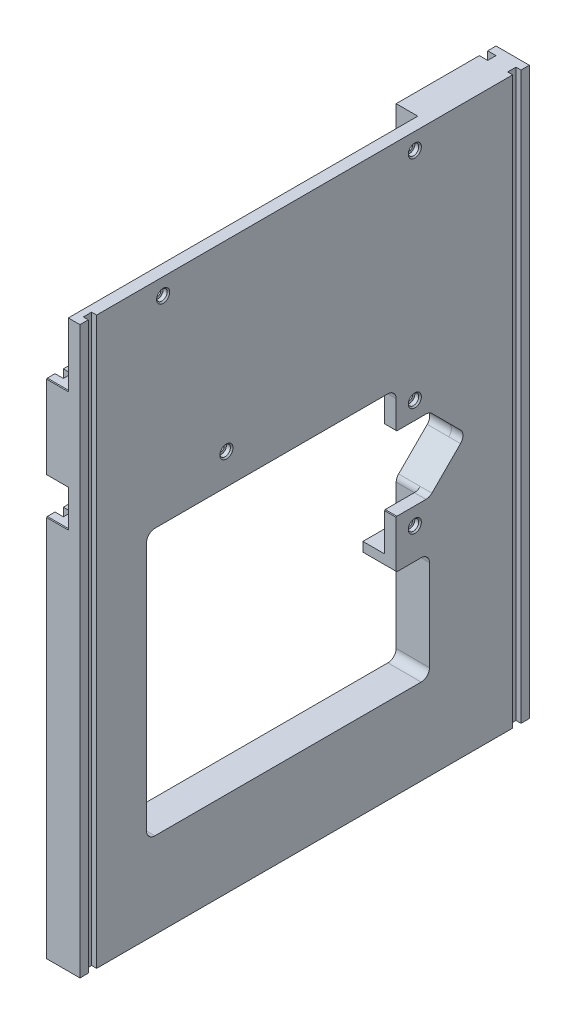
from build123d import *

# Parameters (mm, degrees)
SKETCH2_W                     = 342.9
SKETCH2_H                     = 431.8
BASE_DEPTH                    = 25.4
CUT_EXTRUDE3_REACH            = 27.4
NC_POCKET_DEPTH               = 16.51
FILLET9_R                     = 6.35
FILLET6_R                     = 6.35
CBORE_FOR_M4_SHCS1_AT_2_COUNT = 2
CBORE_FOR_M4_SHCS1_AT_2_PITCH = 192.024
CBORE_FOR_M4_SHCS1_AT_3_COUNT = 2
CBORE_FOR_M4_SHCS1_AT_3_PITCH = 313.675937134
CBORE_FOR_M4_SHCS1_AT_4_COUNT = 2
CBORE_FOR_M4_SHCS1_AT_4_PITCH = 253.241439295
CBORE_FOR_M4_SHCS1_AT_5_COUNT = 2
CBORE_FOR_M4_SHCS1_AT_5_PITCH = 135.860323862
SKETCH18_R                    = 7.1755
CUT_EXTRUDE4_DEPTH            = 1.016
F_3_8_16_TAPPED_HOLE1_D       = 7.9375
F_3_8_16_TAPPED_HOLE1_DEPTH   = 27.94
F_3_8_16_TAPPED_HOLE1_TIP     = 2.384665582
F_3_8_16_TAPPED_HOLE2_D       = 7.9375
F_3_8_16_TAPPED_HOLE2_DEPTH   = 20.32
F_3_8_16_TAPPED_HOLE2_TIP     = 2.384665582
CUT_EXTRUDE5_REACH            = 10.89
FILLET1_R                     = 6.35
FILLET2_R                     = 6.35
CHAMFER1_SIZE                 = 0.508
SKETCH21_W                    = 6.35
SKETCH21_H                    = 431.8
CUT_EXTRUDE6_DEPTH            = 6.35
SKETCH22_W                    = 6.35
SKETCH22_H                    = 431.8
CUT_EXTRUDE7_DEPTH            = 3.81


with BuildPart() as part:
    # Sketch2 → Base (new body)
    with BuildSketch(Plane(origin=(0, 0, 0), x_dir=(0, 0, -1), z_dir=(1, 0, 0))):
        with Locations((-44.038996764, -78.624919094)):
            Rectangle(SKETCH2_W, SKETCH2_H)
    extrude(amount=BASE_DEPTH)

    # Sketch3 → Cut-Extrude3 (cut, up to next)
    with BuildSketch(Plane(origin=(0, 0, 0), x_dir=(0, 0, -1), z_dir=(1, 0, 0)), mode=Mode.PRIVATE) as cut_extrude3_sk1:
        Polygon((-164.688996764, -25.919919094), (-164.688996764, -229.119919094), (51.211003236, -229.119919094), (51.211003236, -146.950919094), (25.811003236, -146.950919094), (25.811003236, -25.919919094), align=None)
    cut_extrude3_tool1 = extrude(cut_extrude3_sk1.sketch, amount=CUT_EXTRUDE3_REACH, mode=Mode.PRIVATE) & part.part
    add(cut_extrude3_tool1.solids().sort_by_distance((0, -130.615794, 63.91645))[0], mode=Mode.SUBTRACT)

    # Sketch4 → NC pocket (cut)
    with BuildSketch(Plane(origin=(0, 0, 0), x_dir=(0, 0, -1), z_dir=(1, 0, 0))):
        Polygon((19.461003236, -18.299919094), (-158.338996764, -18.299919094), (-158.338996764, -25.919919094), (-164.688996764, -25.919919094), (-164.688996764, -12.583714933), (-164.688996764, -2.424919094), (-215.488996764, -2.424919094), (-215.488996764, 24.880080906), (-164.688996764, 24.880080906), (-164.688996764, 89.015080906), (-215.488996764, 89.015080906), (-215.488996764, 90.285080906), (-215.488996764, 137.275080906), (-202.788996764, 137.275080906), (51.211003236, 137.275080906), (51.211003236, -15.124919094), (51.211003236, -53.859919094), (79.405003236, -82.053919094), (51.211003236, -110.247919094), (51.211003236, -136.155919094), (51.211003236, -146.950919094), (44.861003236, -146.950919094), (44.861003236, -139.330919094), (25.811003236, -139.330919094), (25.811003236, -25.919919094), (19.461003236, -25.919919094), align=None)
    extrude(amount=NC_POCKET_DEPTH, mode=Mode.SUBTRACT)

    # Fillet9
    fillet9_edges = [part.edges().sort_by_distance(p)[0] for p in [
        (8.255, -53.859919094, -51.211003236),
        (8.255, -110.247919094, -51.211003236),
    ]]
    fillet(fillet9_edges, radius=FILLET9_R)

    # Fillet6
    fillet6_edges = [part.edges().sort_by_distance(p)[0] for p in [
        (8.255, -82.053919094, -79.405003236),
    ]]
    fillet(fillet6_edges, radius=FILLET6_R)

    # Sketch10 → CBORE for M4 SHCS1 (revolve, cut)
    with BuildSketch(Plane(origin=(25.4, 124.575080906, 151.988996764), x_dir=(0, 0, -1), z_dir=(0, 1, 0))):
        Polygon((0, 0), (0, 8.89), (2.15, 8.89), (2.15, 4), (4, 4), (4, 1), (5, 0), align=None)
    cbore_for_m4_shcs1 = revolve(axis=Axis((31.75, 124.575080906, 151.988996764), (-1, 0, 0)), mode=Mode.SUBTRACT)

    # CBORE for M4 SHCS1 at 2: CBORE for M4 SHCS1 ×2
    with Locations(*[(0, 0, -i * CBORE_FOR_M4_SHCS1_AT_2_PITCH) for i in range(1, CBORE_FOR_M4_SHCS1_AT_2_COUNT)]):
        add(cbore_for_m4_shcs1, mode=Mode.SUBTRACT)

    # CBORE for M4 SHCS1 at 3: CBORE for M4 SHCS1 ×2
    with Locations(*[Vector(0, -0.790723708, -0.612173193) * (i * CBORE_FOR_M4_SHCS1_AT_3_PITCH) for i in range(1, CBORE_FOR_M4_SHCS1_AT_3_COUNT)]):
        add(cbore_for_m4_shcs1, mode=Mode.SUBTRACT)

    # CBORE for M4 SHCS1 at 4: CBORE for M4 SHCS1 ×2
    with Locations(*[Vector(0, -0.651947013, -0.758264526) * (i * CBORE_FOR_M4_SHCS1_AT_4_PITCH) for i in range(1, CBORE_FOR_M4_SHCS1_AT_4_COUNT)]):
        add(cbore_for_m4_shcs1, mode=Mode.SUBTRACT)

    # CBORE for M4 SHCS1 at 5: CBORE for M4 SHCS1 ×2
    with Locations(*[Vector(0, -0.934783581, -0.355217761) * (i * CBORE_FOR_M4_SHCS1_AT_5_PITCH) for i in range(1, CBORE_FOR_M4_SHCS1_AT_5_COUNT)]):
        add(cbore_for_m4_shcs1, mode=Mode.SUBTRACT)

    # Sketch18 → Cut-Extrude4 (cut)
    with BuildSketch(Plane.ZY.offset(-16.51)):
        with Locations((-40.035003236, 124.575080906)):
            Circle(SKETCH18_R)
        with Locations((151.988996764, 124.575080906)):
            Circle(SKETCH18_R)
        with Locations((103.728996764, -2.424919094)):
            Circle(SKETCH18_R)
        with Locations((-40.035003236, -40.524919094)):
            Circle(SKETCH18_R)
        with Locations((-40.035003236, -123.455919094)):
            Circle(SKETCH18_R)
    extrude(amount=-CUT_EXTRUDE4_DEPTH, mode=Mode.SUBTRACT)

    # 3/8-16 Tapped Hole1
    with Locations(Plane(origin=(12.7, -294.524919094, -70.261003236), x_dir=(0, 0, -1), z_dir=(0, -1, 0))):
        with Locations((0, 0), (-114.3, 0), (-228.6, 0)):
            Hole(F_3_8_16_TAPPED_HOLE1_D / 2, depth=F_3_8_16_TAPPED_HOLE1_DEPTH)
            with Locations((0, 0, -(F_3_8_16_TAPPED_HOLE1_DEPTH + F_3_8_16_TAPPED_HOLE1_TIP / 2))):  # 118° drill point
                Cone(0, F_3_8_16_TAPPED_HOLE1_D / 2, F_3_8_16_TAPPED_HOLE1_TIP, mode=Mode.SUBTRACT)

    # 3/8-16 Tapped Hole2
    with Locations(Plane.ZY):
        with Locations((190.088996764, -220.864919094), (190.088996764, -162.444919094), (-102.011003236, -220.864919094), (-102.011003236, -162.444919094)):
            Hole(F_3_8_16_TAPPED_HOLE2_D / 2, depth=F_3_8_16_TAPPED_HOLE2_DEPTH)
            with Locations((0, 0, -(F_3_8_16_TAPPED_HOLE2_DEPTH + F_3_8_16_TAPPED_HOLE2_TIP / 2))):  # 118° drill point
                Cone(0, F_3_8_16_TAPPED_HOLE2_D / 2, F_3_8_16_TAPPED_HOLE2_TIP, mode=Mode.SUBTRACT)

    # Sketch20 → Cut-Extrude5 (cut, up to next)
    with BuildSketch(Plane.ZY.offset(-16.51), mode=Mode.PRIVATE) as cut_extrude5_sk1:
        Polygon((-51.211003236, -53.859919094), (-25.811003236, -53.859919094), (-25.811003236, -110.247919094), (-51.211003236, -110.247919094), (-79.405003236, -82.053919094), align=None)
    cut_extrude5_tool1 = extrude(cut_extrude5_sk1.sketch, amount=-CUT_EXTRUDE5_REACH, mode=Mode.PRIVATE) & part.part
    add(cut_extrude5_tool1.solids().sort_by_distance((16.51, -82.053919, -46.398071))[0], mode=Mode.SUBTRACT)

    # Fillet1
    fillet1_edges = [part.edges().sort_by_distance(p)[0] for p in [
        (20.955, -25.919919094, 164.688996764),
        (12.7, -229.119919094, 164.688996764),
        (12.7, -229.119919094, -51.211003236),
        (20.955, -146.950919094, -51.211003236),
        (20.955, -25.919919094, -25.811003236),
    ]]
    fillet(fillet1_edges, radius=FILLET1_R)

    # Fillet2
    fillet2_edges = [part.edges().sort_by_distance(p)[0] for p in [
        (20.955, -82.053919094, -79.405003236),
        (20.955, -110.247919094, -51.211003236),
        (20.955, -53.859919094, -51.211003236),
    ]]
    fillet(fillet2_edges, radius=FILLET2_R)

    # Chamfer1
    chamfer1_edges = [part.edges().sort_by_distance(p)[0] for p in [
        (12.7, -146.950919094, -25.811003236),
        (20.955, -53.859919094, -25.811003236),
        (20.955, -110.247919094, -25.811003236),
        (8.255, 89.015080906, 215.488996764),
        (8.255, 89.015080906, 164.688996764),
        (8.255, 24.880080906, 164.688996764),
        (8.255, 24.880080906, 215.488996764),
        (8.255, -2.424919094, 215.488996764),
        (8.255, -2.424919094, 164.688996764),
    ]]
    chamfer(chamfer1_edges, length=CHAMFER1_SIZE)

    # Sketch21 → Cut-Extrude6 (cut)
    with BuildSketch(Plane.ZY):
        with Locations((205.963996764, -78.624919094)):
            Rectangle(SKETCH21_W, SKETCH21_H)
        with Locations((-117.886003236, -78.624919094)):
            Rectangle(SKETCH21_W, SKETCH21_H)
    extrude(amount=-CUT_EXTRUDE6_DEPTH, mode=Mode.SUBTRACT)

    # Sketch22 → Cut-Extrude7 (cut)
    with BuildSketch(Plane(origin=(25.4, 0, 0), x_dir=(0, 0, -1), z_dir=(1, 0, 0))):
        with Locations((-205.963996764, -78.624919094)):
            Rectangle(SKETCH22_W, SKETCH22_H)
        with Locations((117.886003236, -78.624919094)):
            Rectangle(SKETCH22_W, SKETCH22_H)
    extrude(amount=-CUT_EXTRUDE7_DEPTH, mode=Mode.SUBTRACT)


solid = part.part
